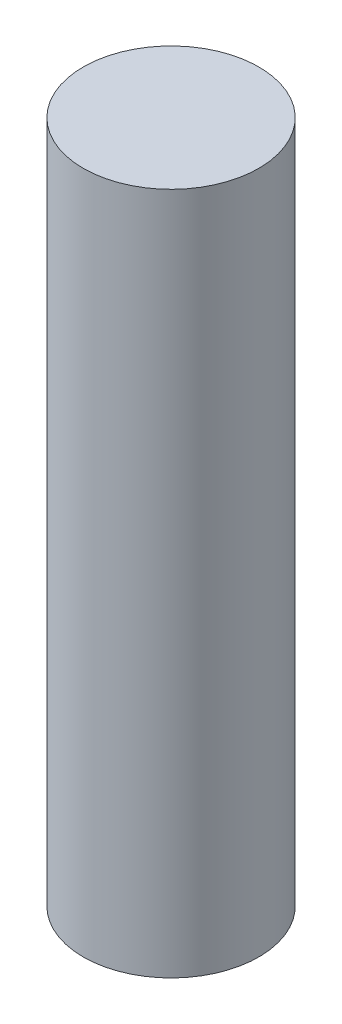
from build123d import *

# Parameters (mm, degrees)
SKETCH2_R           = 9
BOSS_EXTRUDE1_DEPTH = 70
SKETCH3_R           = 7.5
CUT_EXTRUDE1_DEPTH  = 1
SKETCH4_R           = 1.5
CUT_EXTRUDE2_DEPTH  = 50
CHAMFER1_SIZE       = 1
CHAMFER1_SIZE2      = 1.732050808


with BuildPart() as part:
    # Sketch2 → Boss-Extrude1 (new body)
    with BuildSketch(Plane(origin=(0, 0, 0), x_dir=(1, 0, 0), z_dir=(0, 1, 0))):
        Circle(SKETCH2_R)
    extrude(amount=BOSS_EXTRUDE1_DEPTH)

    # Sketch3 → Cut-Extrude1 (cut)
    with BuildSketch(Plane.XZ):
        Circle(SKETCH3_R)
    extrude(amount=-CUT_EXTRUDE1_DEPTH, mode=Mode.SUBTRACT)

    # Sketch4 → Cut-Extrude2 (cut)
    with BuildSketch(Plane.XZ.offset(-1)):
        Circle(SKETCH4_R)
    extrude(amount=-CUT_EXTRUDE2_DEPTH, mode=Mode.SUBTRACT)

    # Chamfer1
    chamfer1_edges = [part.edges().sort_by_distance(p)[0] for p in [
        (-1.5, 1, 0),
    ]]
    chamfer1_side = [part.faces().sort_by_distance(p)[0] for p in [
        (-7.287867966, 1, 0),
    ]]
    chamfer(chamfer1_edges, length=CHAMFER1_SIZE, length2=CHAMFER1_SIZE2, reference=chamfer1_side[0])


solid = part.part
